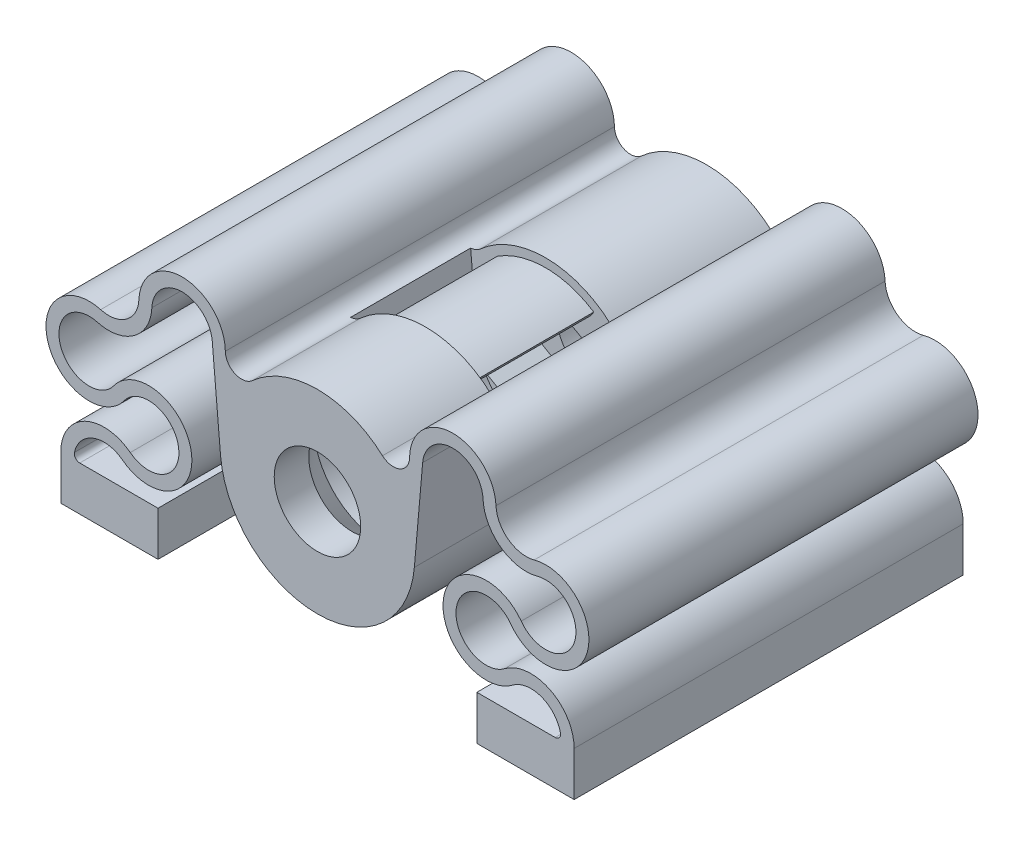
from build123d import *

# Parameters (mm, degrees)
SKETCH1_R           = 4
BOSS_EXTRUDE1_DEPTH = 36
SKETCH2_R           = 2.6
CUT_EXTRUDE1_DEPTH  = 4.2
CUT_EXTRUDE2_START  = -10
CUT_EXTRUDE2_DEPTH  = 11.1
CUT_EXTRUDE3_DEPTH  = 5
BOSS_EXTRUDE2_DEPTH = 11.1


with BuildPart() as part:
    # Sketch1 → Boss-Extrude1 (new body)
    with BuildSketch(Plane.XY):
        with BuildLine():
            Line((-14.75, -7.9), (-14.75, -12))
            Line((-14.75, -12), (-23.75, -12))
            Line((-23.75, -12), (-23.75, -7.9))
            ThreePointArc((-23.75, -7.9), (-21.521408325, -4.313621249), (-17.318943727, -4.723529412))
            ThreePointArc((-17.318943727, -4.723529412), (-12.846321275, -2.097250623), (-17.881535856, -0.852941176))
            ThreePointArc((-17.881535856, -0.852941176), (-24.891297515, 0.177367286), (-20.057391817, 5.357294867))
            ThreePointArc((-20.057391817, 5.357294867), (-17.669207765, 5.792991841), (-16.519021958, 7.930824279))
            ThreePointArc((-16.519021958, 7.930824279), (-12.452765055, 11.749381379), (-8.523313091, 7.790185654))
            ThreePointArc((-8.523313091, 7.790185654), (-7.626821013, 6.431985616), (-6.020047535, 6.690218806))
            ThreePointArc((-6.020047535, 6.690218806), (0, 9), (6.020047535, 6.690218806))
            ThreePointArc((6.020047535, 6.690218806), (7.626821013, 6.431985616), (8.523313091, 7.790185654))
            ThreePointArc((8.523313091, 7.790185654), (12.452765055, 11.749381379), (16.519021958, 7.930824279))
            ThreePointArc((16.519021958, 7.930824279), (17.669207765, 5.792991841), (20.057391817, 5.357294867))
            ThreePointArc((20.057391817, 5.357294867), (24.891297515, 0.177367286), (17.881535856, -0.852941176))
            ThreePointArc((17.881535856, -0.852941176), (12.846321275, -2.097250623), (17.318943727, -4.723529412))
            ThreePointArc((17.318943727, -4.723529412), (21.521408325, -4.313621249), (23.75, -7.9))
            Line((23.75, -7.9), (23.75, -12))
            Line((23.75, -12), (14.75, -12))
            Line((14.75, -12), (14.75, -7.9))
            Line((14.75, -7.9), (21.994994432, -7.9))
            ThreePointArc((21.994994432, -7.9), (22.385089181, -7.712771621), (22.4830367, -7.291304348))
            ThreePointArc((22.4830367, -7.291304348), (20.708026906, -5.268995544), (18.048260609, -5.676470588))
            ThreePointArc((18.048260609, -5.676470588), (11.658799963, -1.924643747), (18.85196365, -0.147058824))
            ThreePointArc((18.85196365, -0.147058824), (23.758796811, 0.5741571), (20.375062823, 4.200106407))
            ThreePointArc((20.375062823, 4.200106407), (16.963371319, 4.822530655), (15.320248738, 7.876576995))
            ThreePointArc((15.320248738, 7.876576995), (12.581969864, 10.5493813), (9.733766071, 7.99403608))
            Line((9.733766071, 7.99403608), (8.965752283, -0.784401685))
            ThreePointArc((8.965752283, -0.784401685), (0, -9), (-8.965752283, -0.784401685))
            Line((-8.965752283, -0.784401685), (-9.733766071, 7.99403608))
            ThreePointArc((-9.733766071, 7.99403608), (-12.581969864, 10.5493813), (-15.320248738, 7.876576995))
            ThreePointArc((-15.320248738, 7.876576995), (-16.963371319, 4.822530655), (-20.375062823, 4.200106407))
            ThreePointArc((-20.375062823, 4.200106407), (-23.758796811, 0.5741571), (-18.85196365, -0.147058824))
            ThreePointArc((-18.85196365, -0.147058824), (-11.658799963, -1.924643747), (-18.048260609, -5.676470588))
            ThreePointArc((-18.048260609, -5.676470588), (-20.708026906, -5.268995544), (-22.4830367, -7.291304348))
            ThreePointArc((-22.4830367, -7.291304348), (-22.385089181, -7.712771621), (-21.994994432, -7.9))
            Line((-21.994994432, -7.9), (-14.75, -7.9))
        make_face()
        Circle(SKETCH1_R, mode=Mode.SUBTRACT)
    extrude(amount=BOSS_EXTRUDE1_DEPTH)

    # Sketch2 → Cut-Extrude1 (cut)
    with BuildSketch(Plane.XZ.offset(12)):
        with Locations(Location((-19.225, 30.5, 0), (0, 0, 270))):  # turned: the seam where the file's is
            Circle(SKETCH2_R)
        with Locations(Location((-19.225, 5.5, 0), (0, 0, 270))):  # turned: the seam where the file's is
            Circle(SKETCH2_R)
        with Locations(Location((19.225, 5.5, 0), (0, 0, 270))):  # turned: the seam where the file's is
            Circle(SKETCH2_R)
        with Locations(Location((19.225, 30.5, 0), (0, 0, 270))):  # turned: the seam where the file's is
            Circle(SKETCH2_R)
    extrude(amount=-CUT_EXTRUDE1_DEPTH, mode=Mode.SUBTRACT)

    # Sketch3 → Cut-Extrude2 (cut)
    with BuildSketch(Plane.XY.offset(36).offset(CUT_EXTRUDE2_START)):
        with BuildLine():
            Line((-7.008961202, 7.254714015), (-6.325836333, -0.553438966))
            ThreePointArc((-6.325836333, -0.553438966), (0, -6.35), (6.325836333, -0.553438966))
            Line((6.325836333, -0.553438966), (7.008961202, 7.254714015))
            ThreePointArc((7.008961202, 7.254714015), (0, 10.087438355), (-7.008961202, 7.254714015))
        make_face()
    extrude(amount=-CUT_EXTRUDE2_DEPTH, mode=Mode.SUBTRACT)

    # Sketch4 → Cut-Revolve1 (revolve, cut)
    with BuildSketch(Plane(origin=(0, 0, 0), x_dir=(1, 0, 0), z_dir=(0, 1, 0))):
        Polygon((0, -14.9), (-6.35, -14.9), (-6.35, -30), (-1.273774508, -36.049609967), (0, -36.049609967), align=None)
    revolve(axis=Axis((0, 0, 14.9), (0, 0, 1)), mode=Mode.SUBTRACT)

    # Sketch5 → Cut-Extrude3 (cut)
    with BuildSketch(Plane.XY.offset(14.9)):
        Polygon((5.35, -3.08882394), (5.35, 3.08882394), (0, 6.17764788), (-5.35, 3.08882394), (-5.35, -3.08882394), (0, -6.17764788), align=None)
    extrude(amount=-CUT_EXTRUDE3_DEPTH, mode=Mode.SUBTRACT)

    # Sketch6 → Boss-Extrude2 (add)
    with BuildSketch(Plane.XY.offset(14.9)):
        with BuildLine():
            Line((-4.466040087, 6.877098657), (-4.19372057, 6.457763373))
            ThreePointArc((-4.19372057, 6.457763373), (0, 7.7), (4.19372057, 6.457763373))
            Line((4.19372057, 6.457763373), (4.466040087, 6.877098657))
            ThreePointArc((4.466040087, 6.877098657), (0, 8.2), (-4.466040087, 6.877098657))
        make_face()
    extrude(amount=BOSS_EXTRUDE2_DEPTH)


solid = part.part
